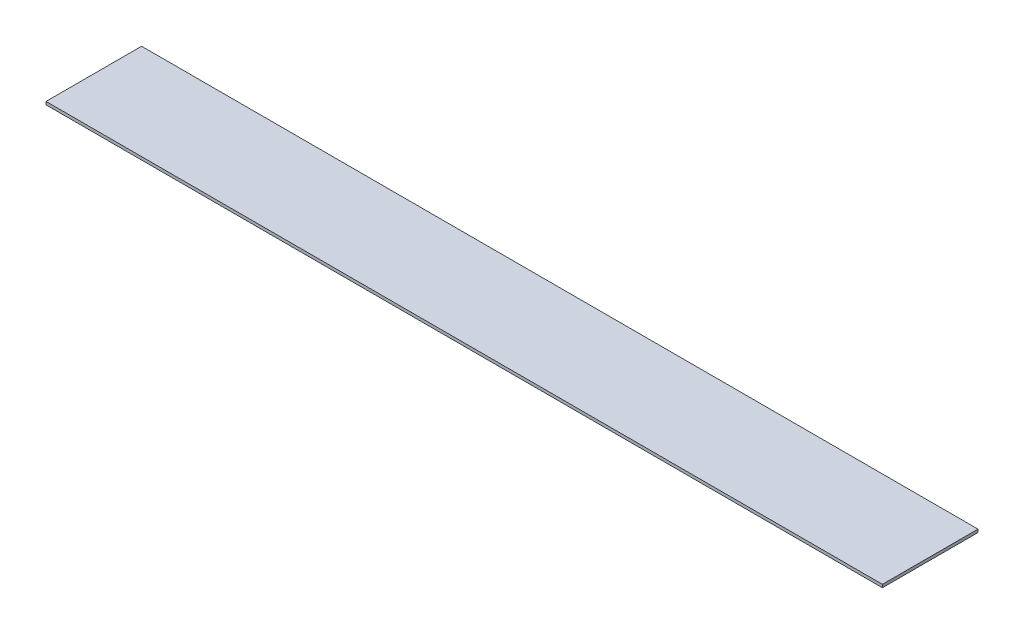
from build123d import *

# Parameters (mm, degrees)
SKETCH1_W           = 444.5
SKETCH1_H           = 50.8
BOSS_EXTRUDE1_DEPTH = 1.5875


with BuildPart() as part:
    # Sketch1 → Boss-Extrude1 (new body)
    with BuildSketch(Plane(origin=(0, 0, 0), x_dir=(1, 0, 0), z_dir=(0, 1, 0))):
        with Locations((222.25, 25.4)):
            Rectangle(SKETCH1_W, SKETCH1_H)
    extrude(amount=BOSS_EXTRUDE1_DEPTH)


solid = part.part
